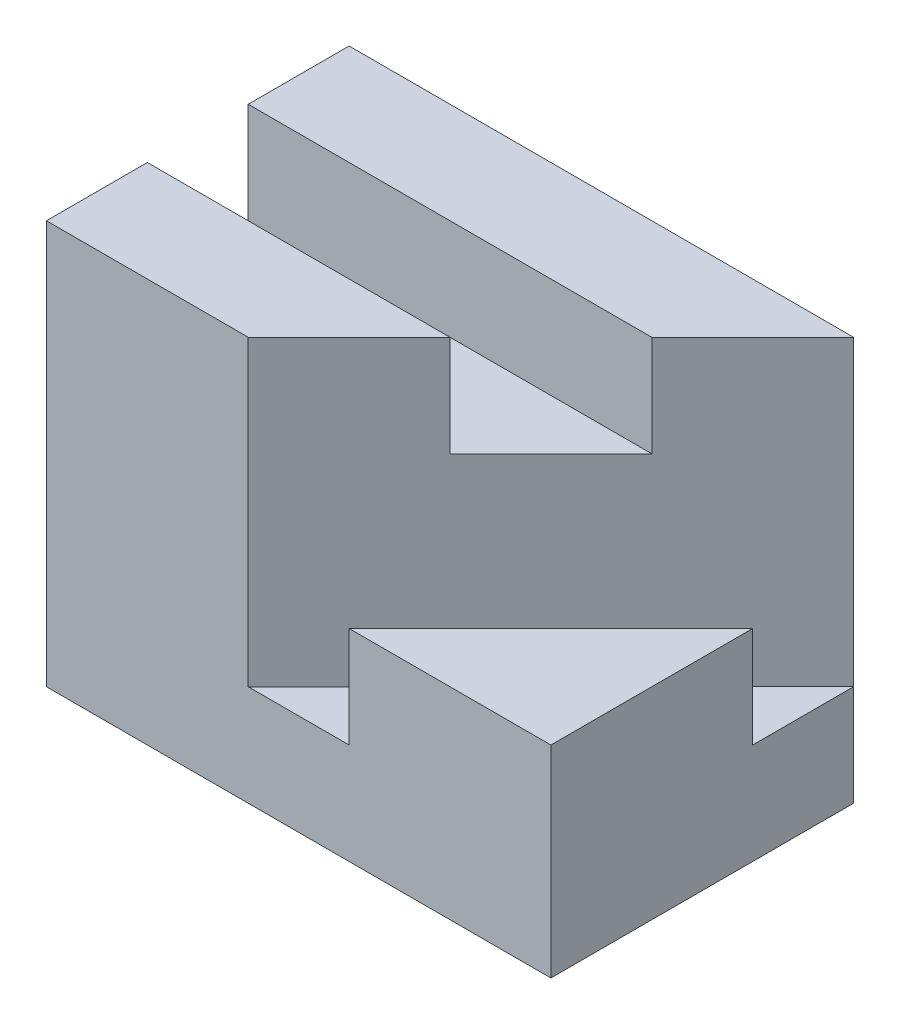
from build123d import *

# Parameters (mm, degrees)
SKETCH_1_W          = 5
SKETCH_1_H          = 3
EXTRUDE_1_DEPTH     = 4
CUT_EXTRUDE_1_DEPTH = 1
CUT_EXTRUDE_2_DEPTH = 3
CUT_EXTRUDE_3_DEPTH = 2


with BuildPart() as part:
    # 草圖1 → 填料-伸長1 (new body)
    with BuildSketch(Plane(origin=(0, 0, 0), x_dir=(1, 0, 0), z_dir=(0, 1, 0))):
        Rectangle(SKETCH_1_W, SKETCH_1_H)
    extrude(amount=EXTRUDE_1_DEPTH)

    # 草圖3 → 除料-伸長1 (cut)
    with BuildSketch(Plane(origin=(0, 4, 0), x_dir=(1, 0, 0), z_dir=(0, 1, 0))):
        Polygon((-2.5, 0.5), (-2.5, -0.5), (0.5, -0.5), (-0.5, -1.5), (2.5, -1.5), (2.5, 1.5), (1.5, 0.5), align=None)
    extrude(amount=-CUT_EXTRUDE_1_DEPTH, mode=Mode.SUBTRACT)

    # 草圖3<3> → 除料-伸長2 (cut)
    with BuildSketch(Plane(origin=(0, 4, 0), x_dir=(1, 0, 0), z_dir=(0, 1, 0))):
        Polygon((1.5, 0.5), (0.5, -0.5), (-0.5, -1.5), (0.5, -1.5), (2.5, 0.5), (2.5, 1.5), align=None)
    extrude(amount=-CUT_EXTRUDE_2_DEPTH, mode=Mode.SUBTRACT)

    # 草圖3<4> → 除料-伸長3 (cut)
    with BuildSketch(Plane(origin=(0, 4, 0), x_dir=(1, 0, 0), z_dir=(0, 1, 0))):
        Polygon((2.5, 0.5), (0.5, -1.5), (2.5, -1.5), align=None)
    extrude(amount=-CUT_EXTRUDE_3_DEPTH, mode=Mode.SUBTRACT)


solid = part.part
